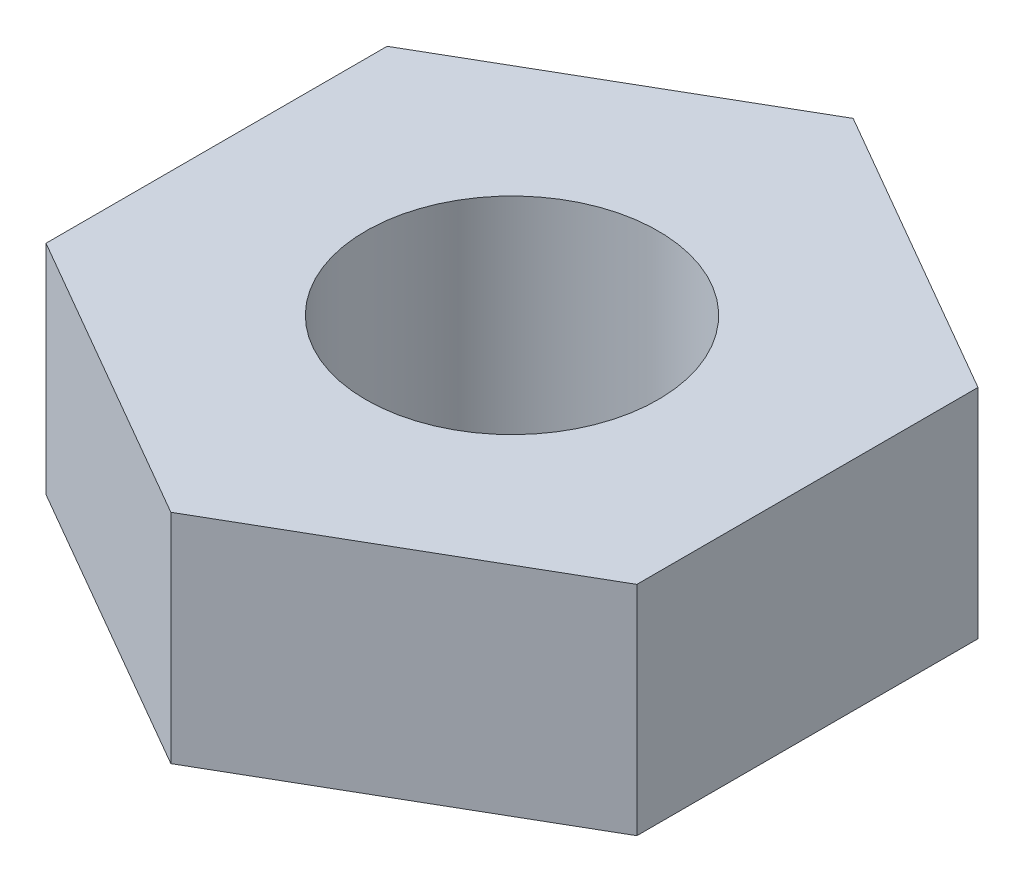
from build123d import *

# Parameters (mm, degrees)
CROQUIS1_R              = 2.35
SALIENTE_EXTRUIR1_DEPTH = 3.5


with BuildPart() as part:
    # Croquis1 → Saliente-Extruir1 (new body)
    with BuildSketch(Plane(origin=(0, 0, 0), x_dir=(1, 0, 0), z_dir=(0, 1, 0))):
        Polygon((0, 5.484827557), (-4.75, 2.742413779), (-4.75, -2.742413779), (0, -5.484827557), (4.75, -2.742413779), (4.75, 2.742413779), align=None)
        Circle(CROQUIS1_R, mode=Mode.SUBTRACT)
    extrude(amount=SALIENTE_EXTRUIR1_DEPTH)


solid = part.part
